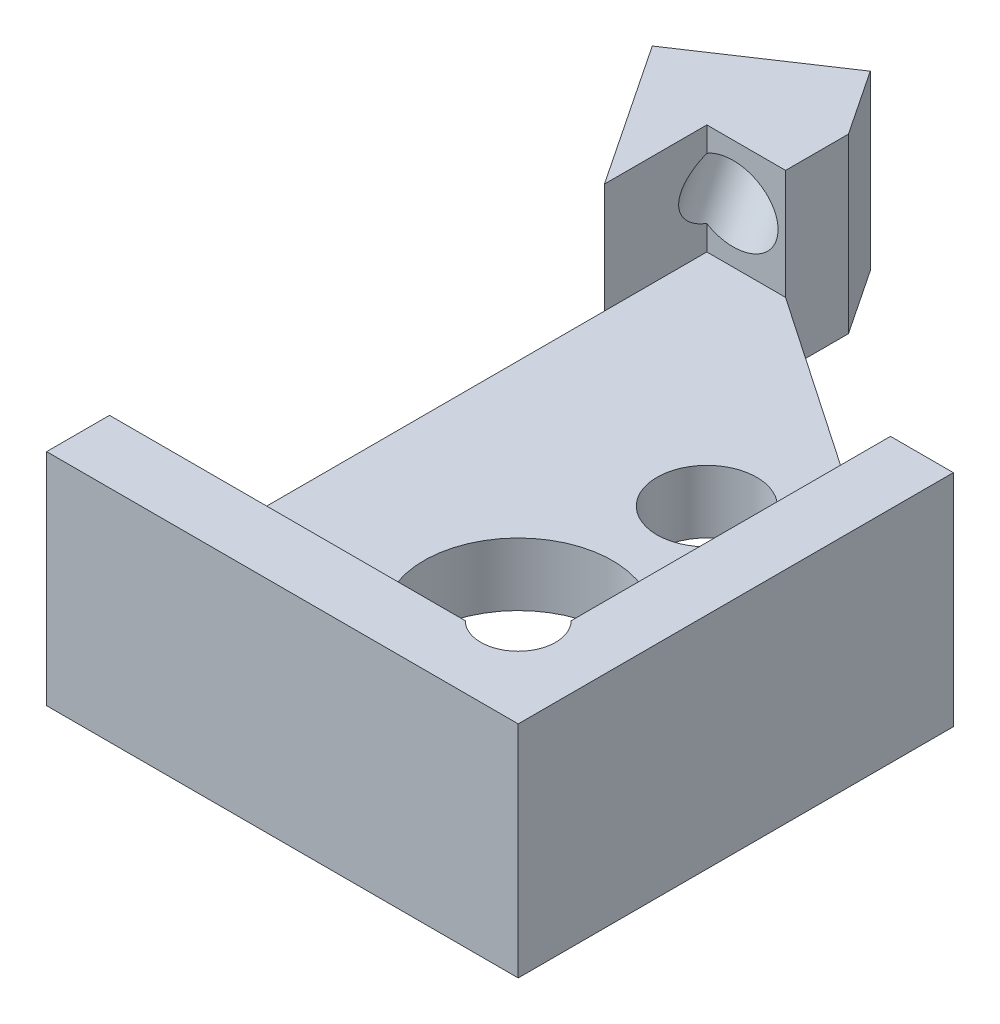
from build123d import *

# Parameters (mm, degrees)
SKETCH1_W                     = 8.5
SKETCH1_H                     = 11.5
BOSS_EXTRUDE1_DEPTH           = 3.5
CUT_EXTRUDE1_START            = -2.5
SKETCH2_W                     = 6.5
SKETCH2_H                     = 9.5
CUT_EXTRUDE1_DEPTH            = 2.5
SKETCH3_R                     = 1.5
CUT_EXTRUDE2_DEPTH            = 2
SKETCH6_R                     = 0.5953125
CUT_EXTRUDE5_DEPTH            = 2.5
SKETCH7_R                     = 0.79375
CUT_EXTRUDE6_DEPTH            = 2
BOSS_EXTRUDE2_DEPTH           = 3.5
SKETCH14_W                    = 5.965258944
SKETCH14_H                    = 5.132960456
CUT_EXTRUDE8_DEPTH            = 0.75
TAP_DRILL_FOR_0_80_TAP1_D     = 1.19126
TAP_DRILL_FOR_0_80_TAP1_DEPTH = 7.11
TAP_DRILL_FOR_0_80_TAP1_TIP   = 0.357890611
CUT_EXTRUDE7_REACH            = 5.5


with BuildPart() as part:
    # Sketch1 → Boss-Extrude1 (new body)
    with BuildSketch(Plane(origin=(0, 0, 0), x_dir=(1, 0, 0), z_dir=(0, 1, 0))):
        Rectangle(SKETCH1_W, SKETCH1_H)
    extrude(amount=BOSS_EXTRUDE1_DEPTH)

    # Sketch2 → Cut-Extrude1 (cut)
    with BuildSketch(Plane(origin=(0, 3.5, 0), x_dir=(1, 0, 0), z_dir=(0, 1, 0)).offset(CUT_EXTRUDE1_START)):
        Rectangle(SKETCH2_W, SKETCH2_H)
    extrude(amount=CUT_EXTRUDE1_DEPTH, mode=Mode.SUBTRACT)

    # Sketch3 → Cut-Extrude2 (cut, through all)
    with BuildSketch(Plane(origin=(0, 1, 0), x_dir=(1, 0, 0), z_dir=(0, 1, 0))):
        with Locations((0.25, -1.75)):
            Circle(SKETCH3_R)
    extrude(amount=-CUT_EXTRUDE2_DEPTH, mode=Mode.SUBTRACT)

    # Sketch6 → Cut-Extrude5 (cut)
    with BuildSketch(Plane(origin=(0, 3.5, 0), x_dir=(1, 0, 0), z_dir=(0, 1, 0))):
        with Locations((2.829050494, -4.329050494)):
            Circle(SKETCH6_R)
    extrude(amount=-CUT_EXTRUDE5_DEPTH, mode=Mode.SUBTRACT)

    # Sketch7 → Cut-Extrude6 (cut, through all)
    with BuildSketch(Plane(origin=(0, 1, 0), x_dir=(1, 0, 0), z_dir=(0, 1, 0))):
        with Locations((0.25, 1.25)):
            Circle(SKETCH7_R)
        with Locations((-1.625, -3.5)):
            Circle(SKETCH7_R)
        with Locations((2.125, -3.5)):
            Circle(SKETCH7_R)
    extrude(amount=-CUT_EXTRUDE6_DEPTH, mode=Mode.SUBTRACT)

    # Sketch9 → Boss-Extrude2 (add)
    with BuildSketch(Plane(origin=(0, 3.5, 0), x_dir=(1, 0, 0), z_dir=(0, 1, 0))):
        Polygon((-2.69064642, 6.789569053), (-4.770772156, 5.402818562), (-4.001541387, 4.248972409), (-3.411634369, 4.642243754), (-2.511322669, 5.242451554), (-1.921415651, 5.635722899), align=None)
    extrude(amount=-BOSS_EXTRUDE2_DEPTH)

    # Sketch14 → Cut-Extrude8 (cut)
    with BuildSketch(Plane(origin=(0, 3.5, 0), x_dir=(1, 0, 0), z_dir=(0, 1, 0))):
        with Locations((-3.25, 4.75)):
            Rectangle(SKETCH14_W, SKETCH14_H)
    extrude(amount=-CUT_EXTRUDE8_DEPTH, mode=Mode.SUBTRACT)

    # Tap Drill for #0-80 Tap1
    with Locations(Plane(origin=(-3.961538462, 0, -5.942307692), x_dir=(-0.832050294, 0, 0.554700196), z_dir=(-0.554700196, 0, -0.832050294))):
        with Locations((-0.27742214, 1.875)):
            Hole(TAP_DRILL_FOR_0_80_TAP1_D / 2, depth=TAP_DRILL_FOR_0_80_TAP1_DEPTH)
            with Locations((0, 0, -(TAP_DRILL_FOR_0_80_TAP1_DEPTH + TAP_DRILL_FOR_0_80_TAP1_TIP / 2))):  # 118° drill point
                Cone(0, TAP_DRILL_FOR_0_80_TAP1_D / 2, TAP_DRILL_FOR_0_80_TAP1_TIP, mode=Mode.SUBTRACT)

    # Sketch13 → Cut-Extrude7 (cut, up to next)
    with BuildSketch(Plane(origin=(0, 3.5, 0), x_dir=(1, 0, 0), z_dir=(0, 1, 0)), mode=Mode.PRIVATE) as cut_extrude7_sk1:
        Polygon((-1.997600385, 5.75), (-1.997600385, 4.75), (3.25, 1.170806318), (4.25, 1.170806318), (4.25, 5.75), align=None)
    cut_extrude7_tool1 = extrude(cut_extrude7_sk1.sketch, amount=-CUT_EXTRUDE7_REACH, mode=Mode.PRIVATE) & part.part
    add(cut_extrude7_tool1.solids().sort_by_distance((1.797917, 3.5, -3.996239))[0], mode=Mode.SUBTRACT)
    # Sketch13 → Cut-Extrude7 (cut, up to next)
    with BuildSketch(Plane(origin=(0, 3.5, 0), x_dir=(1, 0, 0), z_dir=(0, 1, 0)), mode=Mode.PRIVATE) as cut_extrude7_sk2:
        Polygon((-4.25, 4.621660328), (-3.25, 3.121660328), (-3.25, -5.75), (-4.25, -5.75), align=None)
    cut_extrude7_tool2 = extrude(cut_extrude7_sk2.sketch, amount=-CUT_EXTRUDE7_REACH, mode=Mode.PRIVATE) & part.part
    add(cut_extrude7_tool2.solids().sort_by_distance((-3.762992, 3.5, 0.929426))[0], mode=Mode.SUBTRACT)


solid = part.part
